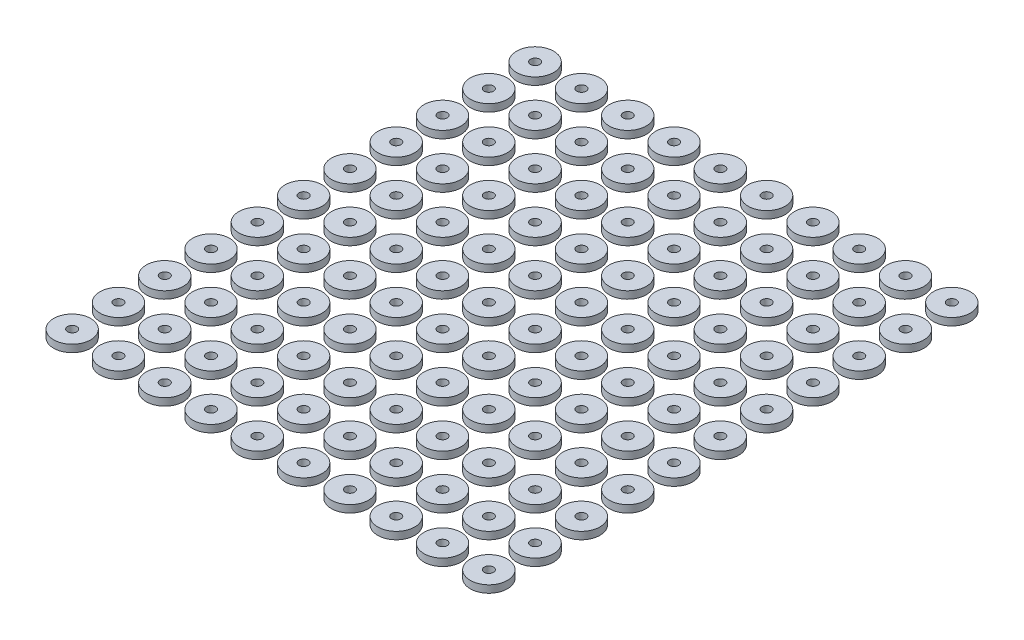
from build123d import *

# Parameters (mm, degrees)
SKETCH1_R           = 4
SKETCH1_R_2         = 1
BOSS_EXTRUDE1_DEPTH = 1.5875


with BuildPart() as part:
    # Sketch1 → Boss-Extrude1 (new body)
    with BuildSketch(Plane(origin=(0, 0, 0), x_dir=(1, 0, 0), z_dir=(0, 1, 0))):
        Circle(SKETCH1_R)
        Circle(SKETCH1_R_2, mode=Mode.SUBTRACT)
        with Locations((10, 0)):
            Circle(SKETCH1_R)
        with Locations((10, 0)):
            Circle(SKETCH1_R_2, mode=Mode.SUBTRACT)
        with Locations((20, 0)):
            Circle(SKETCH1_R)
        with Locations((20, 0)):
            Circle(SKETCH1_R_2, mode=Mode.SUBTRACT)
        with Locations((30, 0)):
            Circle(SKETCH1_R)
        with Locations((30, 0)):
            Circle(SKETCH1_R_2, mode=Mode.SUBTRACT)
        with Locations((40, 0)):
            Circle(SKETCH1_R)
        with Locations((40, 0)):
            Circle(SKETCH1_R_2, mode=Mode.SUBTRACT)
        with Locations((50, 0)):
            Circle(SKETCH1_R)
        with Locations((50, 0)):
            Circle(SKETCH1_R_2, mode=Mode.SUBTRACT)
        with Locations((60, 0)):
            Circle(SKETCH1_R)
        with Locations((60, 0)):
            Circle(SKETCH1_R_2, mode=Mode.SUBTRACT)
        with Locations((70, 0)):
            Circle(SKETCH1_R)
        with Locations((70, 0)):
            Circle(SKETCH1_R_2, mode=Mode.SUBTRACT)
        with Locations((80, 0)):
            Circle(SKETCH1_R)
        with Locations((80, 0)):
            Circle(SKETCH1_R_2, mode=Mode.SUBTRACT)
        with Locations((90, 0)):
            Circle(SKETCH1_R)
        with Locations((90, 0)):
            Circle(SKETCH1_R_2, mode=Mode.SUBTRACT)
        with Locations((10, 10)):
            Circle(SKETCH1_R)
        with Locations((10, 10)):
            Circle(SKETCH1_R_2, mode=Mode.SUBTRACT)
        with Locations((20, 10)):
            Circle(SKETCH1_R)
        with Locations((20, 10)):
            Circle(SKETCH1_R_2, mode=Mode.SUBTRACT)
        with Locations((30, 10)):
            Circle(SKETCH1_R)
        with Locations((30, 10)):
            Circle(SKETCH1_R_2, mode=Mode.SUBTRACT)
        with Locations((40, 10)):
            Circle(SKETCH1_R)
        with Locations((40, 10)):
            Circle(SKETCH1_R_2, mode=Mode.SUBTRACT)
        with Locations((50, 10)):
            Circle(SKETCH1_R)
        with Locations((50, 10)):
            Circle(SKETCH1_R_2, mode=Mode.SUBTRACT)
        with Locations((60, 10)):
            Circle(SKETCH1_R)
        with Locations((60, 10)):
            Circle(SKETCH1_R_2, mode=Mode.SUBTRACT)
        with Locations((70, 10)):
            Circle(SKETCH1_R)
        with Locations((70, 10)):
            Circle(SKETCH1_R_2, mode=Mode.SUBTRACT)
        with Locations((80, 10)):
            Circle(SKETCH1_R)
        with Locations((80, 10)):
            Circle(SKETCH1_R_2, mode=Mode.SUBTRACT)
        with Locations((90, 10)):
            Circle(SKETCH1_R)
        with Locations((90, 10)):
            Circle(SKETCH1_R_2, mode=Mode.SUBTRACT)
        with Locations((10, 20)):
            Circle(SKETCH1_R)
        with Locations((10, 20)):
            Circle(SKETCH1_R_2, mode=Mode.SUBTRACT)
        with Locations((20, 20)):
            Circle(SKETCH1_R)
        with Locations((20, 20)):
            Circle(SKETCH1_R_2, mode=Mode.SUBTRACT)
        with Locations((30, 20)):
            Circle(SKETCH1_R)
        with Locations((30, 20)):
            Circle(SKETCH1_R_2, mode=Mode.SUBTRACT)
        with Locations((40, 20)):
            Circle(SKETCH1_R)
        with Locations((40, 20)):
            Circle(SKETCH1_R_2, mode=Mode.SUBTRACT)
        with Locations((50, 20)):
            Circle(SKETCH1_R)
        with Locations((50, 20)):
            Circle(SKETCH1_R_2, mode=Mode.SUBTRACT)
        with Locations((60, 20)):
            Circle(SKETCH1_R)
        with Locations((60, 20)):
            Circle(SKETCH1_R_2, mode=Mode.SUBTRACT)
        with Locations((70, 20)):
            Circle(SKETCH1_R)
        with Locations((70, 20)):
            Circle(SKETCH1_R_2, mode=Mode.SUBTRACT)
        with Locations((80, 20)):
            Circle(SKETCH1_R)
        with Locations((80, 20)):
            Circle(SKETCH1_R_2, mode=Mode.SUBTRACT)
        with Locations((90, 20)):
            Circle(SKETCH1_R)
        with Locations((90, 20)):
            Circle(SKETCH1_R_2, mode=Mode.SUBTRACT)
        with Locations((10, 30)):
            Circle(SKETCH1_R)
        with Locations((10, 30)):
            Circle(SKETCH1_R_2, mode=Mode.SUBTRACT)
        with Locations((20, 30)):
            Circle(SKETCH1_R)
        with Locations((20, 30)):
            Circle(SKETCH1_R_2, mode=Mode.SUBTRACT)
        with Locations((30, 30)):
            Circle(SKETCH1_R)
        with Locations((30, 30)):
            Circle(SKETCH1_R_2, mode=Mode.SUBTRACT)
        with Locations((40, 30)):
            Circle(SKETCH1_R)
        with Locations((40, 30)):
            Circle(SKETCH1_R_2, mode=Mode.SUBTRACT)
        with Locations((50, 30)):
            Circle(SKETCH1_R)
        with Locations((50, 30)):
            Circle(SKETCH1_R_2, mode=Mode.SUBTRACT)
        with Locations((60, 30)):
            Circle(SKETCH1_R)
        with Locations((60, 30)):
            Circle(SKETCH1_R_2, mode=Mode.SUBTRACT)
        with Locations((70, 30)):
            Circle(SKETCH1_R)
        with Locations((70, 30)):
            Circle(SKETCH1_R_2, mode=Mode.SUBTRACT)
        with Locations((80, 30)):
            Circle(SKETCH1_R)
        with Locations((80, 30)):
            Circle(SKETCH1_R_2, mode=Mode.SUBTRACT)
        with Locations((90, 30)):
            Circle(SKETCH1_R)
        with Locations((90, 30)):
            Circle(SKETCH1_R_2, mode=Mode.SUBTRACT)
        with Locations((10, 40)):
            Circle(SKETCH1_R)
        with Locations((10, 40)):
            Circle(SKETCH1_R_2, mode=Mode.SUBTRACT)
        with Locations((20, 40)):
            Circle(SKETCH1_R)
        with Locations((20, 40)):
            Circle(SKETCH1_R_2, mode=Mode.SUBTRACT)
        with Locations((30, 40)):
            Circle(SKETCH1_R)
        with Locations((30, 40)):
            Circle(SKETCH1_R_2, mode=Mode.SUBTRACT)
        with Locations((40, 40)):
            Circle(SKETCH1_R)
        with Locations((40, 40)):
            Circle(SKETCH1_R_2, mode=Mode.SUBTRACT)
        with Locations((50, 40)):
            Circle(SKETCH1_R)
        with Locations((50, 40)):
            Circle(SKETCH1_R_2, mode=Mode.SUBTRACT)
        with Locations((60, 40)):
            Circle(SKETCH1_R)
        with Locations((60, 40)):
            Circle(SKETCH1_R_2, mode=Mode.SUBTRACT)
        with Locations((70, 40)):
            Circle(SKETCH1_R)
        with Locations((70, 40)):
            Circle(SKETCH1_R_2, mode=Mode.SUBTRACT)
        with Locations((80, 40)):
            Circle(SKETCH1_R)
        with Locations((80, 40)):
            Circle(SKETCH1_R_2, mode=Mode.SUBTRACT)
        with Locations((90, 40)):
            Circle(SKETCH1_R)
        with Locations((90, 40)):
            Circle(SKETCH1_R_2, mode=Mode.SUBTRACT)
        with Locations((10, 50)):
            Circle(SKETCH1_R)
        with Locations((10, 50)):
            Circle(SKETCH1_R_2, mode=Mode.SUBTRACT)
        with Locations((20, 50)):
            Circle(SKETCH1_R)
        with Locations((20, 50)):
            Circle(SKETCH1_R_2, mode=Mode.SUBTRACT)
        with Locations((30, 50)):
            Circle(SKETCH1_R)
        with Locations((30, 50)):
            Circle(SKETCH1_R_2, mode=Mode.SUBTRACT)
        with Locations((40, 50)):
            Circle(SKETCH1_R)
        with Locations((40, 50)):
            Circle(SKETCH1_R_2, mode=Mode.SUBTRACT)
        with Locations((50, 50)):
            Circle(SKETCH1_R)
        with Locations((50, 50)):
            Circle(SKETCH1_R_2, mode=Mode.SUBTRACT)
        with Locations((60, 50)):
            Circle(SKETCH1_R)
        with Locations((60, 50)):
            Circle(SKETCH1_R_2, mode=Mode.SUBTRACT)
        with Locations((70, 50)):
            Circle(SKETCH1_R)
        with Locations((70, 50)):
            Circle(SKETCH1_R_2, mode=Mode.SUBTRACT)
        with Locations((80, 50)):
            Circle(SKETCH1_R)
        with Locations((80, 50)):
            Circle(SKETCH1_R_2, mode=Mode.SUBTRACT)
        with Locations((90, 50)):
            Circle(SKETCH1_R)
        with Locations((90, 50)):
            Circle(SKETCH1_R_2, mode=Mode.SUBTRACT)
        with Locations((10, 60)):
            Circle(SKETCH1_R)
        with Locations((10, 60)):
            Circle(SKETCH1_R_2, mode=Mode.SUBTRACT)
        with Locations((20, 60)):
            Circle(SKETCH1_R)
        with Locations((20, 60)):
            Circle(SKETCH1_R_2, mode=Mode.SUBTRACT)
        with Locations((30, 60)):
            Circle(SKETCH1_R)
        with Locations((30, 60)):
            Circle(SKETCH1_R_2, mode=Mode.SUBTRACT)
        with Locations((40, 60)):
            Circle(SKETCH1_R)
        with Locations((40, 60)):
            Circle(SKETCH1_R_2, mode=Mode.SUBTRACT)
        with Locations((50, 60)):
            Circle(SKETCH1_R)
        with Locations((50, 60)):
            Circle(SKETCH1_R_2, mode=Mode.SUBTRACT)
        with Locations((60, 60)):
            Circle(SKETCH1_R)
        with Locations((60, 60)):
            Circle(SKETCH1_R_2, mode=Mode.SUBTRACT)
        with Locations((70, 60)):
            Circle(SKETCH1_R)
        with Locations((70, 60)):
            Circle(SKETCH1_R_2, mode=Mode.SUBTRACT)
        with Locations((80, 60)):
            Circle(SKETCH1_R)
        with Locations((80, 60)):
            Circle(SKETCH1_R_2, mode=Mode.SUBTRACT)
        with Locations((90, 60)):
            Circle(SKETCH1_R)
        with Locations((90, 60)):
            Circle(SKETCH1_R_2, mode=Mode.SUBTRACT)
        with Locations((10, 70)):
            Circle(SKETCH1_R)
        with Locations((10, 70)):
            Circle(SKETCH1_R_2, mode=Mode.SUBTRACT)
        with Locations((20, 70)):
            Circle(SKETCH1_R)
        with Locations((20, 70)):
            Circle(SKETCH1_R_2, mode=Mode.SUBTRACT)
        with Locations((30, 70)):
            Circle(SKETCH1_R)
        with Locations((30, 70)):
            Circle(SKETCH1_R_2, mode=Mode.SUBTRACT)
        with Locations((40, 70)):
            Circle(SKETCH1_R)
        with Locations((40, 70)):
            Circle(SKETCH1_R_2, mode=Mode.SUBTRACT)
        with Locations((50, 70)):
            Circle(SKETCH1_R)
        with Locations((50, 70)):
            Circle(SKETCH1_R_2, mode=Mode.SUBTRACT)
        with Locations((60, 70)):
            Circle(SKETCH1_R)
        with Locations((60, 70)):
            Circle(SKETCH1_R_2, mode=Mode.SUBTRACT)
        with Locations((70, 70)):
            Circle(SKETCH1_R)
        with Locations((70, 70)):
            Circle(SKETCH1_R_2, mode=Mode.SUBTRACT)
        with Locations((80, 70)):
            Circle(SKETCH1_R)
        with Locations((80, 70)):
            Circle(SKETCH1_R_2, mode=Mode.SUBTRACT)
        with Locations((90, 70)):
            Circle(SKETCH1_R)
        with Locations((90, 70)):
            Circle(SKETCH1_R_2, mode=Mode.SUBTRACT)
        with Locations((10, 80)):
            Circle(SKETCH1_R)
        with Locations((10, 80)):
            Circle(SKETCH1_R_2, mode=Mode.SUBTRACT)
        with Locations((20, 80)):
            Circle(SKETCH1_R)
        with Locations((20, 80)):
            Circle(SKETCH1_R_2, mode=Mode.SUBTRACT)
        with Locations((30, 80)):
            Circle(SKETCH1_R)
        with Locations((30, 80)):
            Circle(SKETCH1_R_2, mode=Mode.SUBTRACT)
        with Locations((40, 80)):
            Circle(SKETCH1_R)
        with Locations((40, 80)):
            Circle(SKETCH1_R_2, mode=Mode.SUBTRACT)
        with Locations((50, 80)):
            Circle(SKETCH1_R)
        with Locations((50, 80)):
            Circle(SKETCH1_R_2, mode=Mode.SUBTRACT)
        with Locations((60, 80)):
            Circle(SKETCH1_R)
        with Locations((60, 80)):
            Circle(SKETCH1_R_2, mode=Mode.SUBTRACT)
        with Locations((70, 80)):
            Circle(SKETCH1_R)
        with Locations((70, 80)):
            Circle(SKETCH1_R_2, mode=Mode.SUBTRACT)
        with Locations((80, 80)):
            Circle(SKETCH1_R)
        with Locations((80, 80)):
            Circle(SKETCH1_R_2, mode=Mode.SUBTRACT)
        with Locations((90, 80)):
            Circle(SKETCH1_R)
        with Locations((90, 80)):
            Circle(SKETCH1_R_2, mode=Mode.SUBTRACT)
        with Locations((10, 90)):
            Circle(SKETCH1_R)
        with Locations((10, 90)):
            Circle(SKETCH1_R_2, mode=Mode.SUBTRACT)
        with Locations((20, 90)):
            Circle(SKETCH1_R)
        with Locations((20, 90)):
            Circle(SKETCH1_R_2, mode=Mode.SUBTRACT)
        with Locations((30, 90)):
            Circle(SKETCH1_R)
        with Locations((30, 90)):
            Circle(SKETCH1_R_2, mode=Mode.SUBTRACT)
        with Locations((40, 90)):
            Circle(SKETCH1_R)
        with Locations((40, 90)):
            Circle(SKETCH1_R_2, mode=Mode.SUBTRACT)
        with Locations((50, 90)):
            Circle(SKETCH1_R)
        with Locations((50, 90)):
            Circle(SKETCH1_R_2, mode=Mode.SUBTRACT)
        with Locations((60, 90)):
            Circle(SKETCH1_R)
        with Locations((60, 90)):
            Circle(SKETCH1_R_2, mode=Mode.SUBTRACT)
        with Locations((70, 90)):
            Circle(SKETCH1_R)
        with Locations((70, 90)):
            Circle(SKETCH1_R_2, mode=Mode.SUBTRACT)
        with Locations((80, 90)):
            Circle(SKETCH1_R)
        with Locations((80, 90)):
            Circle(SKETCH1_R_2, mode=Mode.SUBTRACT)
        with Locations((90, 90)):
            Circle(SKETCH1_R)
        with Locations((90, 90)):
            Circle(SKETCH1_R_2, mode=Mode.SUBTRACT)
        with Locations((10, 100)):
            Circle(SKETCH1_R)
        with Locations((10, 100)):
            Circle(SKETCH1_R_2, mode=Mode.SUBTRACT)
        with Locations((20, 100)):
            Circle(SKETCH1_R)
        with Locations((20, 100)):
            Circle(SKETCH1_R_2, mode=Mode.SUBTRACT)
        with Locations((30, 100)):
            Circle(SKETCH1_R)
        with Locations((30, 100)):
            Circle(SKETCH1_R_2, mode=Mode.SUBTRACT)
        with Locations((40, 100)):
            Circle(SKETCH1_R)
        with Locations((40, 100)):
            Circle(SKETCH1_R_2, mode=Mode.SUBTRACT)
        with Locations((50, 100)):
            Circle(SKETCH1_R)
        with Locations((50, 100)):
            Circle(SKETCH1_R_2, mode=Mode.SUBTRACT)
        with Locations((60, 100)):
            Circle(SKETCH1_R)
        with Locations((60, 100)):
            Circle(SKETCH1_R_2, mode=Mode.SUBTRACT)
        with Locations((70, 100)):
            Circle(SKETCH1_R)
        with Locations((70, 100)):
            Circle(SKETCH1_R_2, mode=Mode.SUBTRACT)
        with Locations((80, 100)):
            Circle(SKETCH1_R)
        with Locations((80, 100)):
            Circle(SKETCH1_R_2, mode=Mode.SUBTRACT)
        with Locations((90, 100)):
            Circle(SKETCH1_R)
        with Locations((90, 100)):
            Circle(SKETCH1_R_2, mode=Mode.SUBTRACT)
        with Locations((0, 10)):
            Circle(SKETCH1_R)
        with Locations((0, 10)):
            Circle(SKETCH1_R_2, mode=Mode.SUBTRACT)
        with Locations((0, 20)):
            Circle(SKETCH1_R)
        with Locations((0, 20)):
            Circle(SKETCH1_R_2, mode=Mode.SUBTRACT)
        with Locations((0, 30)):
            Circle(SKETCH1_R)
        with Locations((0, 30)):
            Circle(SKETCH1_R_2, mode=Mode.SUBTRACT)
        with Locations((0, 40)):
            Circle(SKETCH1_R)
        with Locations((0, 40)):
            Circle(SKETCH1_R_2, mode=Mode.SUBTRACT)
        with Locations((0, 50)):
            Circle(SKETCH1_R)
        with Locations((0, 50)):
            Circle(SKETCH1_R_2, mode=Mode.SUBTRACT)
        with Locations((0, 60)):
            Circle(SKETCH1_R)
        with Locations((0, 60)):
            Circle(SKETCH1_R_2, mode=Mode.SUBTRACT)
        with Locations((0, 70)):
            Circle(SKETCH1_R)
        with Locations((0, 70)):
            Circle(SKETCH1_R_2, mode=Mode.SUBTRACT)
        with Locations((0, 80)):
            Circle(SKETCH1_R)
        with Locations((0, 80)):
            Circle(SKETCH1_R_2, mode=Mode.SUBTRACT)
        with Locations((0, 90)):
            Circle(SKETCH1_R)
        with Locations((0, 90)):
            Circle(SKETCH1_R_2, mode=Mode.SUBTRACT)
        with Locations((0, 100)):
            Circle(SKETCH1_R)
        with Locations((0, 100)):
            Circle(SKETCH1_R_2, mode=Mode.SUBTRACT)
    extrude(amount=BOSS_EXTRUDE1_DEPTH)


solid = part.part
